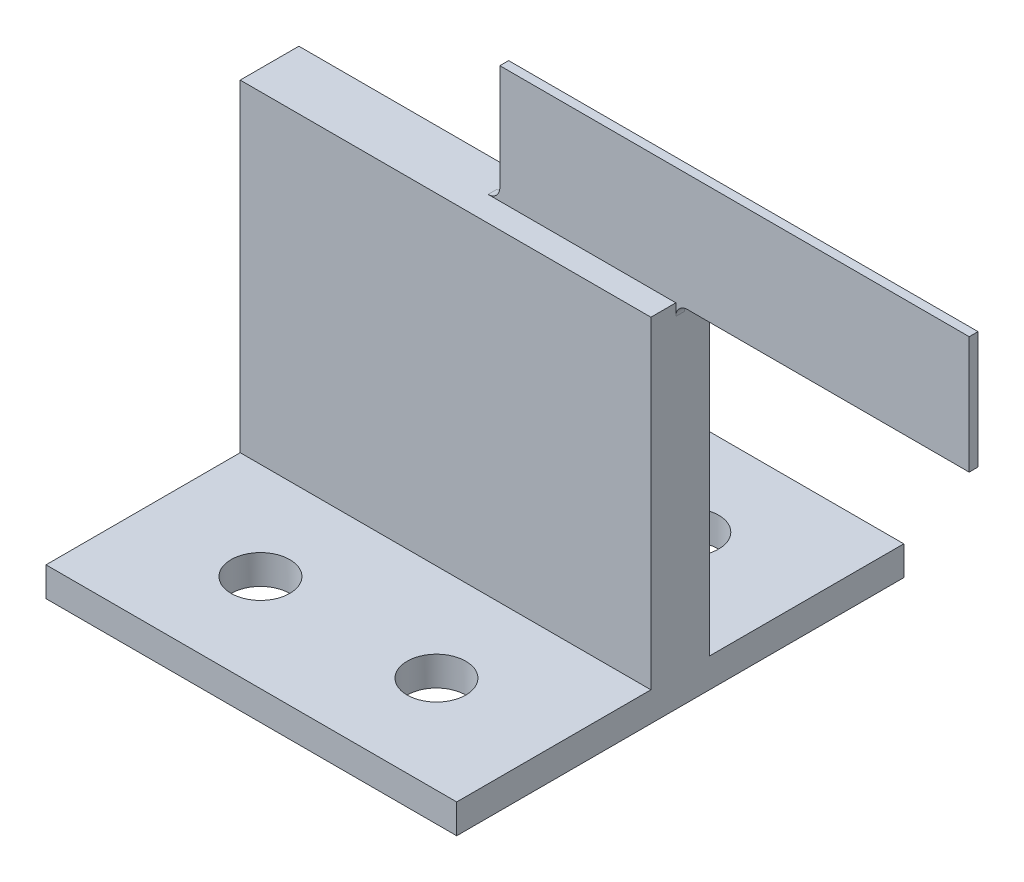
from build123d import *

# Parameters (mm, degrees)
ESQUISSE1_W             = 35
ESQUISSE1_H             = 5
BOSS_EXTRU_1_DEPTH      = 30
ESQUISSE2_W             = 40
ESQUISSE2_H             = 0.75
BOSS_EXTRU_2_DEPTH      = 10
CONG_1_R                = 1
ESQUISSE3_W             = 35
ESQUISSE3_H             = 38.1
BOSS_EXTRU_3_DEPTH      = 2.5
ESQUISSE4_R             = 2.5
ENL_V_MAT_EXTRU_1_DEPTH = 2.5


with BuildPart() as part:
    # Esquisse1 → Boss.-Extru.1 (new body)
    with BuildSketch(Plane(origin=(0, 0, 0), x_dir=(1, 0, 0), z_dir=(0, 1, 0))):
        Rectangle(ESQUISSE1_W, ESQUISSE1_H)
    extrude(amount=BOSS_EXTRU_1_DEPTH)

    # Esquisse2 → Boss.-Extru.2 (add)
    with BuildSketch(Plane(origin=(0, 30, 0), x_dir=(1, 0, 0), z_dir=(0, 1, 0))):
        with Locations((22.5, 0)):
            Rectangle(ESQUISSE2_W, ESQUISSE2_H)
    extrude(amount=BOSS_EXTRU_2_DEPTH)

    # Congé1
    cong_1_edges = [part.edges().sort_by_distance(p)[0] for p in [
        (17.5, 30, 0),
        (2.5, 30, 0),
    ]]
    fillet(cong_1_edges, radius=CONG_1_R)

    # Esquisse3 → Boss.-Extru.3 (add)
    with BuildSketch(Plane.XZ):
        Rectangle(ESQUISSE3_W, ESQUISSE3_H)
    extrude(amount=-BOSS_EXTRU_3_DEPTH)

    # Esquisse4 → Enlèv. mat.-Extru.1 (cut)
    with BuildSketch(Plane(origin=(0, 2.5, 0), x_dir=(1, 0, 0), z_dir=(0, 1, 0))):
        with Locations((-7.5, 10.775)):
            Circle(ESQUISSE4_R)
        with Locations((7.5, 10.775)):
            Circle(ESQUISSE4_R)
        with Locations((7.5, -10.775)):
            Circle(ESQUISSE4_R)
        with Locations((-7.5, -10.775)):
            Circle(ESQUISSE4_R)
    extrude(amount=-ENL_V_MAT_EXTRU_1_DEPTH, mode=Mode.SUBTRACT)


solid = part.part
